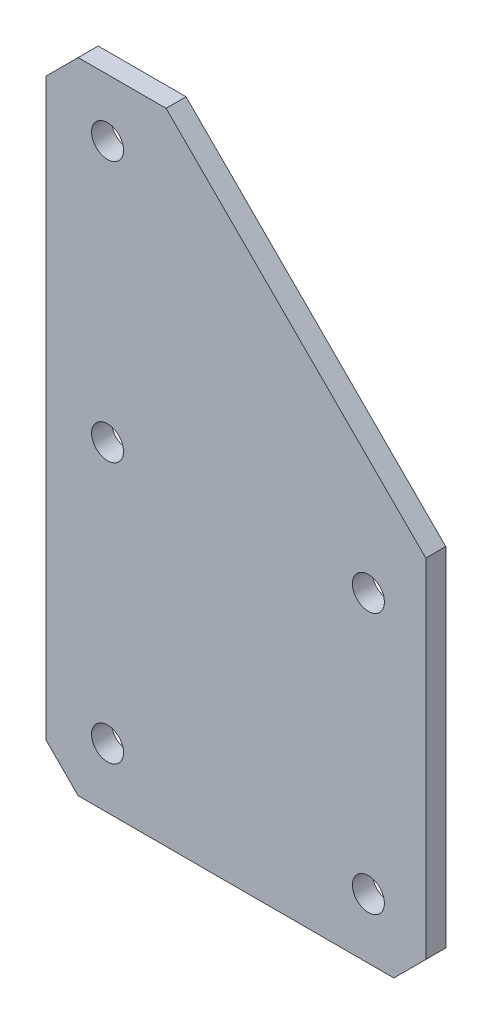
from build123d import *

# Parameters (mm, degrees)
BOSS_EXTRUDE1_DEPTH = 3.175
SKETCH2_R           = 2.54
CUT_EXTRUDE1_DEPTH  = 4.175
CHAMFER1_SIZE       = 5.08


with BuildPart() as part:
    # Sketch1 → Boss-Extrude1 (new body)
    with BuildSketch(Plane.XY):
        Polygon((-95.364356197, 10.475976437), (-35.039356197, 10.475976437), (-35.039356197, 70.800976437), (-76.314356197, 112.075976437), (-95.364356197, 112.075976437), align=None)
    extrude(amount=BOSS_EXTRUDE1_DEPTH)

    # Sketch2 → Cut-Extrude1 (cut, through all)
    with BuildSketch(Plane(origin=(0, 0, 0), x_dir=(-1, 0, 0), z_dir=(0, 0, -1))):
        with Locations((44.162734276, 20.000976437)):
            Circle(SKETCH2_R)
        with Locations((85.617120669, 20.000976437)):
            Circle(SKETCH2_R)
        with Locations((85.617120669, 61.45536283)):
            Circle(SKETCH2_R)
        with Locations((85.617120669, 102.909749223)):
            Circle(SKETCH2_R)
        with Locations((44.162734276, 61.45536283)):
            Circle(SKETCH2_R)
    extrude(amount=-CUT_EXTRUDE1_DEPTH, mode=Mode.SUBTRACT)

    # Chamfer1
    chamfer1_edges = [part.edges().sort_by_distance(p)[0] for p in [
        (-95.364356197, 112.075976437, 1.5875),
        (-35.039356197, 10.475976437, 1.5875),
        (-95.364356197, 10.475976437, 1.5875),
    ]]
    chamfer(chamfer1_edges, length=CHAMFER1_SIZE)


solid = part.part
